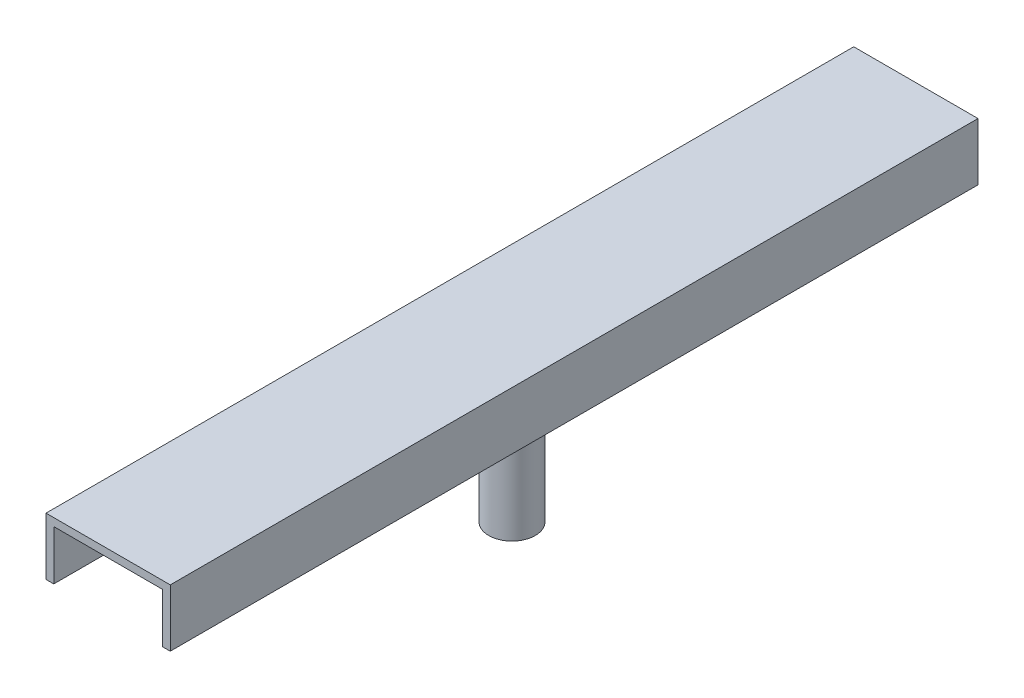
from build123d import *

# Parameters (mm, degrees)
BOSS_EXTRUDE1_DEPTH = 330.2
SKETCH2_R           = 19.05
BOSS_EXTRUDE2_DEPTH = 139.7


with BuildPart() as part:
    # Sketch1 → Boss-Extrude1 (new body, symmetric)
    with BuildSketch(Plane.XY):
        Polygon((-50.8, -23.495), (-44.45, -23.495), (-44.45, 17.145), (44.45, 17.145), (44.45, -23.495), (50.8, -23.495), (50.8, 23.495), (-50.8, 23.495), align=None)
    extrude(amount=BOSS_EXTRUDE1_DEPTH, both=True)

    # Sketch2 → Boss-Extrude2 (add)
    with BuildSketch(Plane.XZ.offset(-17.145)):
        Circle(SKETCH2_R)
    extrude(amount=BOSS_EXTRUDE2_DEPTH)


solid = part.part
